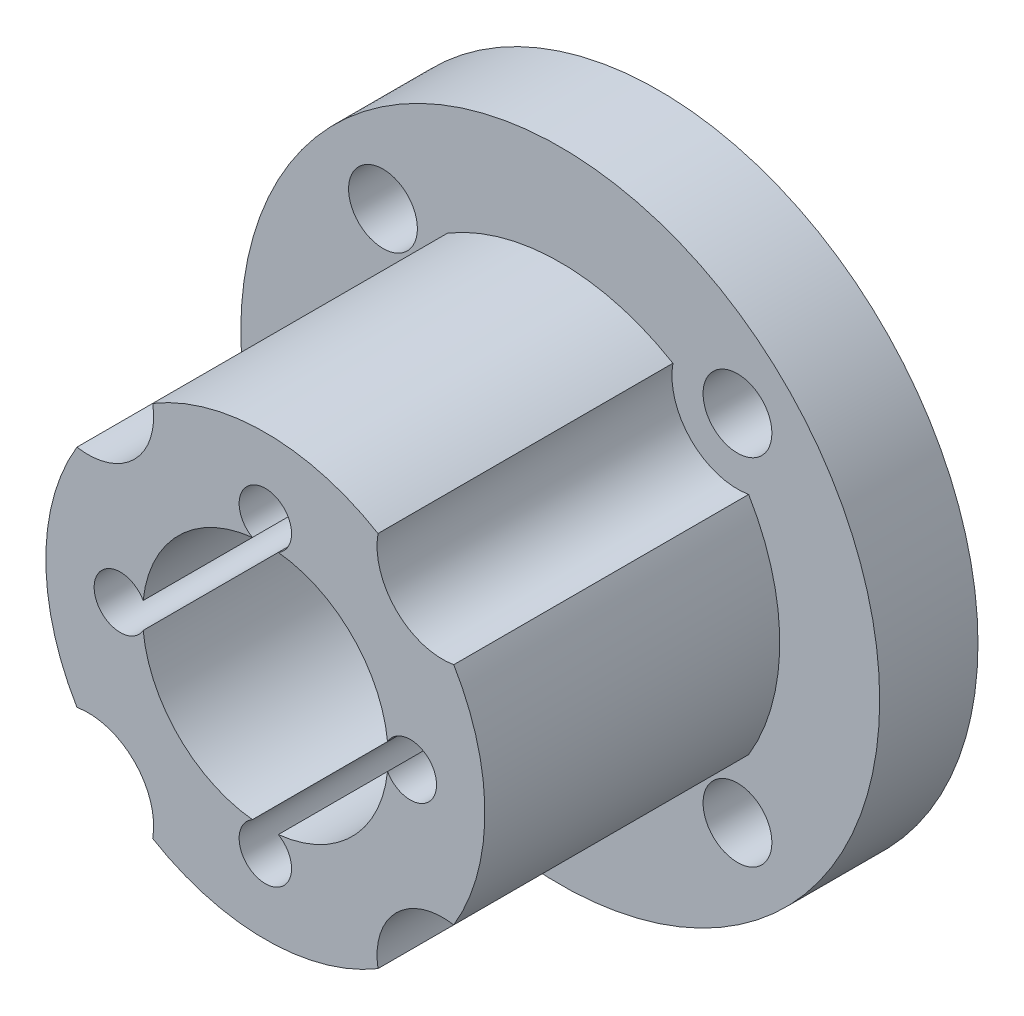
from build123d import *

# Parameters (mm, degrees)
SKIZZE1_R                       = 6.7
SKIZZE1_R_2                     = 3.75
AUFSATZ_LINEAR_AUSTRAGEN1_DEPTH = 9
SKIZZE1_7_R                     = 9.75
SKIZZE1_7_R_2                   = 3.75
AUFSATZ_LINEAR_AUSTRAGEN2_DEPTH = 3
M2_GEWINDEBOHRUNG1_D            = 1.6
SKIZZE5_R                       = 1.05
SCHNITT_LINEAR_AUSTRAGEN1_DEPTH = 13
SKIZZE5_3_R                     = 2
SKIZZE5_3_R_2                   = 1.05
SCHNITT_LINEAR_AUSTRAGEN2_DEPTH = 9


with BuildPart() as part:
    # Skizze1 → Aufsatz-Linear austragen1 (new body)
    with BuildSketch(Plane.XY):
        Circle(SKIZZE1_R)
        Circle(SKIZZE1_R_2, mode=Mode.SUBTRACT)
    extrude(amount=AUFSATZ_LINEAR_AUSTRAGEN1_DEPTH)

    # Skizze1_7 → Aufsatz-Linear austragen2 (add)
    with BuildSketch(Plane.XY):
        Circle(SKIZZE1_7_R)
        Circle(SKIZZE1_7_R_2, mode=Mode.SUBTRACT)
    extrude(amount=-AUFSATZ_LINEAR_AUSTRAGEN2_DEPTH)

    # M2 Gewindebohrung1 (through all)
    with Locations(Plane.XY.offset(9)):
        with Locations((4.425, 0), (0, -4.425), (-4.425, 0), (0, 4.425)):
            Hole(M2_GEWINDEBOHRUNG1_D / 2)

    # Skizze5 → Schnitt-Linear austragen1 (cut, through all)
    with BuildSketch(Plane.XY.offset(9)):
        with Locations((5.409366876, 5.409366876)):
            Circle(SKIZZE5_R)
        with Locations((5.409366876, -5.409366876)):
            Circle(SKIZZE5_R)
        with Locations((-5.409366876, -5.409366876)):
            Circle(SKIZZE5_R)
        with Locations((-5.409366876, 5.409366876)):
            Circle(SKIZZE5_R)
    extrude(amount=-SCHNITT_LINEAR_AUSTRAGEN1_DEPTH, mode=Mode.SUBTRACT)

    # Skizze5_3 → Schnitt-Linear austragen2 (cut)
    with BuildSketch(Plane.XY.offset(9)):
        with Locations((-5.409366876, 5.409366876)):
            Circle(SKIZZE5_3_R)
        with Locations((-5.409366876, 5.409366876)):
            Circle(SKIZZE5_3_R_2, mode=Mode.SUBTRACT)
        with Locations((5.409366876, 5.409366876)):
            Circle(SKIZZE5_3_R)
        with Locations((5.409366876, 5.409366876)):
            Circle(SKIZZE5_3_R_2, mode=Mode.SUBTRACT)
        with Locations((5.409366876, -5.409366876)):
            Circle(SKIZZE5_3_R)
        with Locations((5.409366876, -5.409366876)):
            Circle(SKIZZE5_3_R_2, mode=Mode.SUBTRACT)
        with Locations((-5.409366876, -5.409366876)):
            Circle(SKIZZE5_3_R)
        with Locations((-5.409366876, -5.409366876)):
            Circle(SKIZZE5_3_R_2, mode=Mode.SUBTRACT)
    extrude(amount=-SCHNITT_LINEAR_AUSTRAGEN2_DEPTH, mode=Mode.SUBTRACT)


solid = part.part
